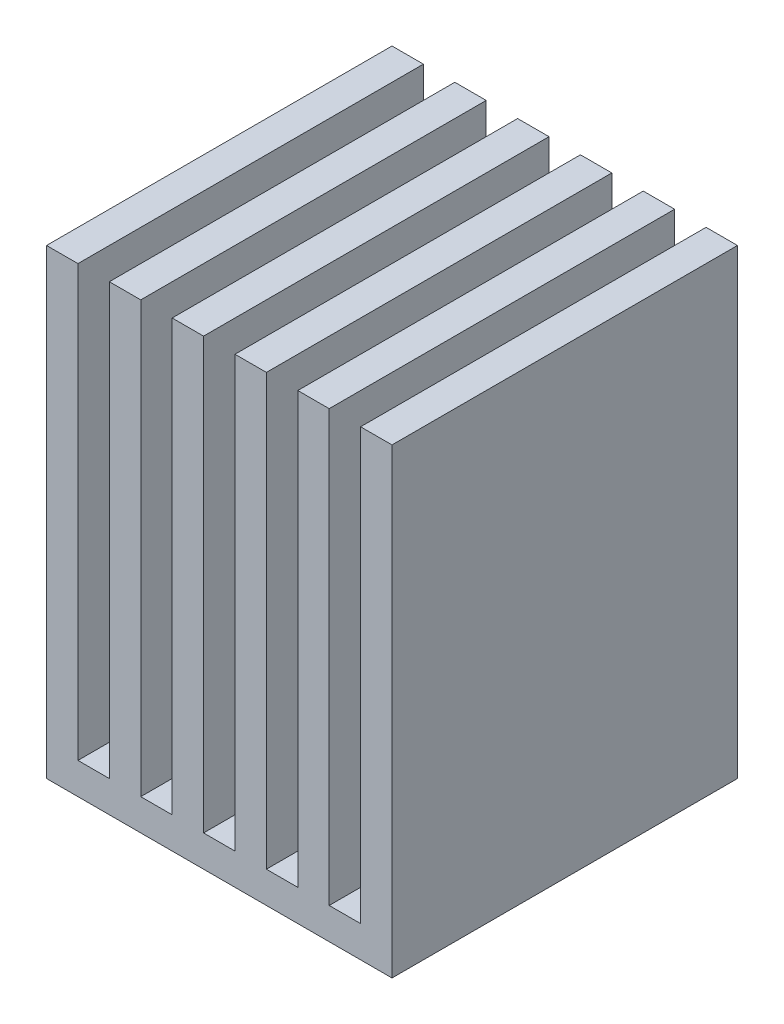
from build123d import *

# Parameters (mm, degrees)
SKETCH3_W           = 40
SKETCH3_H           = 40
BOSS_EXTRUDE2_DEPTH = 5
BOSS_EXTRUDE3_DEPTH = 55


with BuildPart() as part:
    # Sketch3 → Boss-Extrude2 (new body, symmetric)
    with BuildSketch(Plane(origin=(0, 0, 0), x_dir=(1, 0, 0), z_dir=(0, 1, 0))):
        Rectangle(SKETCH3_W, SKETCH3_H)
    extrude(amount=BOSS_EXTRUDE2_DEPTH, both=True)

    # Sketch9 → Boss-Extrude3 (add, symmetric)
    with BuildSketch(Plane.XY):
        Polygon((-55, 5), (55, 5), (55, 152), (45, 152), (45, 15), (35, 15), (35, 152), (25, 152), (25, 15), (15, 15), (15, 152), (5, 152), (5, 15), (-5, 15), (-5, 152), (-15, 152), (-15, 15), (-25, 15), (-25, 152), (-35, 152), (-35, 15), (-45, 15), (-45, 152), (-55, 152), align=None)
    extrude(amount=BOSS_EXTRUDE3_DEPTH, both=True)


solid = part.part
